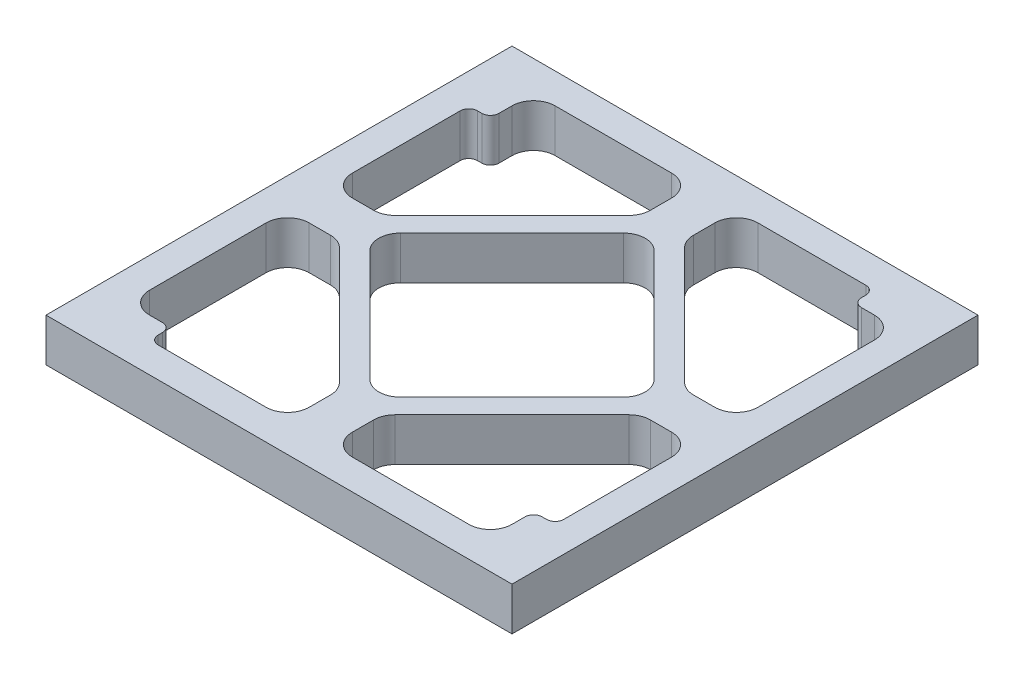
from build123d import *

# Parameters (mm, degrees)
SKETCH1_W           = 108
SKETCH1_H           = 108
BOSS_EXTRUDE1_DEPTH = 10
FILLET1_R           = 5
FILLET3_R           = 2


with BuildPart() as part:
    # Sketch1 → Boss-Extrude1 (new body)
    with BuildSketch(Plane(origin=(0, 0, 0), x_dir=(1, 0, 0), z_dir=(0, 1, 0))):
        Rectangle(SKETCH1_W, SKETCH1_H)
        Polygon((-42, 47), (-42, 37), (-47, 37), (-47, 5), (-35, 5), (-5, 35), (-5, 47), align=None, mode=Mode.SUBTRACT)
        Polygon((-32.928932188, 0), (0, 32.928932188), (32.928932188, 0), (0, -32.928932188), align=None, mode=Mode.SUBTRACT)
        Polygon((5, 47), (5, 35), (35, 5), (47, 5), (47, 42), (37, 42), (37, 47), align=None, mode=Mode.SUBTRACT)
        Polygon((47, -5), (35, -5), (5, -35), (5, -47), (42, -47), (42, -37), (47, -37), align=None, mode=Mode.SUBTRACT)
        Polygon((-5, -47), (-5, -35), (-35, -5), (-47, -5), (-47, -42), (-37, -42), (-37, -47), align=None, mode=Mode.SUBTRACT)
    extrude(amount=BOSS_EXTRUDE1_DEPTH)

    # Fillet1
    fillet1_edges = [part.edges().sort_by_distance(p)[0] for p in [
        (32.928932188, 5, 0),
        (0, 5, 32.928932188),
        (-32.928932188, 5, 0),
        (0, 5, -32.928932188),
        (-5, 5, -47),
        (-5, 5, -35),
        (-35, 5, -5),
        (-47, 5, 42),
        (-47, 5, 5),
        (-35, 5, 5),
        (-5, 5, 35),
        (-5, 5, 47),
        (42, 5, 47),
        (47, 5, 5),
        (35, 5, 5),
        (5, 5, 35),
        (5, 5, 47),
        (47, 5, -42),
        (47, 5, -5),
        (35, 5, -5),
        (5, 5, -35),
        (5, 5, -47),
        (-42, 5, -47),
        (-47, 5, -5),
    ]]
    fillet(fillet1_edges, radius=FILLET1_R)

    # Fillet3
    fillet3_edges = [part.edges().sort_by_distance(p)[0] for p in [
        (-37, 5, 42),
        (-37, 5, 47),
        (42, 5, 37),
        (47, 5, 37),
        (37, 5, -42),
        (37, 5, -47),
        (-47, 5, -37),
        (-42, 5, -37),
    ]]
    fillet(fillet3_edges, radius=FILLET3_R)


solid = part.part
